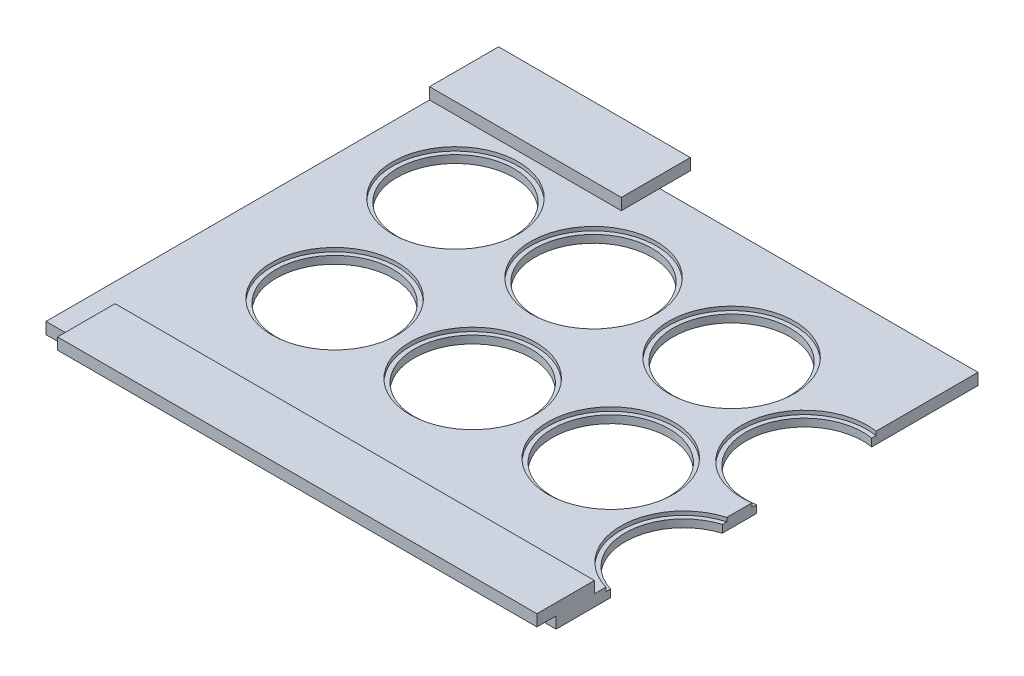
from build123d import *

# Parameters (mm, degrees)
SKETCH1_W           = 133
SKETCH1_H           = 110
BOSS_EXTRUDE1_DEPTH = 3
SKETCH2_W           = 50
SKETCH2_H           = 18
BOSS_EXTRUDE2_DEPTH = 3
SKETCH3_W           = 125
SKETCH3_H           = 15
BOSS_EXTRUDE3_DEPTH = 3
SKETCH4_R           = 15.25
CUT_EXTRUDE1_DEPTH  = 3
SKETCH5_R           = 16.375
CUT_EXTRUDE2_DEPTH  = 1


with BuildPart() as part:
    # Sketch1 → Boss-Extrude1 (new body)
    with BuildSketch(Plane(origin=(0, 0, 0), x_dir=(1, 0, 0), z_dir=(0, 1, 0))):
        with Locations((66.5, 55)):
            Rectangle(SKETCH1_W, SKETCH1_H)
    extrude(amount=BOSS_EXTRUDE1_DEPTH)

    # Sketch2 → Boss-Extrude2 (add)
    with BuildSketch(Plane(origin=(0, 3, 0), x_dir=(1, 0, 0), z_dir=(0, 1, 0))):
        with Locations((25, 109)):
            Rectangle(SKETCH2_W, SKETCH2_H)
    extrude(amount=BOSS_EXTRUDE2_DEPTH)

    # Sketch3 → Boss-Extrude3 (add)
    with BuildSketch(Plane(origin=(0, 3, 0), x_dir=(1, 0, 0), z_dir=(0, 1, 0))):
        with Locations((70.5, 2.5)):
            Rectangle(SKETCH3_W, SKETCH3_H)
    extrude(amount=BOSS_EXTRUDE3_DEPTH)

    # Sketch4 → Cut-Extrude1 (cut)
    with BuildSketch(Plane.XZ):
        with Locations((25.5, -81.25)):
            Circle(SKETCH4_R)
        with Locations((32.5, -42.75)):
            Circle(SKETCH4_R)
        with Locations((61.5, -81.25)):
            Circle(SKETCH4_R)
        with Locations((97.5, -81.25)):
            Circle(SKETCH4_R)
        with Locations((130.5, -67.25)):
            Circle(SKETCH4_R)
        with Locations((68.5, -42.75)):
            Circle(SKETCH4_R)
        with Locations((104.5, -42.75)):
            Circle(SKETCH4_R)
        with Locations((137.5, -28.75)):
            Circle(SKETCH4_R)
    extrude(amount=-CUT_EXTRUDE1_DEPTH, mode=Mode.SUBTRACT)

    # Sketch5 → Cut-Extrude2 (cut)
    with BuildSketch(Plane(origin=(0, 3, 0), x_dir=(1, 0, 0), z_dir=(0, 1, 0))):
        with Locations((25.5, 81.25)):
            Circle(SKETCH5_R)
        with Locations((61.5, 81.25)):
            Circle(SKETCH5_R)
        with Locations((97.5, 81.25)):
            Circle(SKETCH5_R)
        with Locations((32.5, 42.75)):
            Circle(SKETCH5_R)
        with Locations((68.5, 42.75)):
            Circle(SKETCH5_R)
        with Locations((104.5, 42.75)):
            Circle(SKETCH5_R)
        with Locations((130.5, 67.25)):
            Circle(SKETCH5_R)
        with Locations((137.5, 28.75)):
            Circle(SKETCH5_R)
    extrude(amount=-CUT_EXTRUDE2_DEPTH, mode=Mode.SUBTRACT)


solid = part.part
